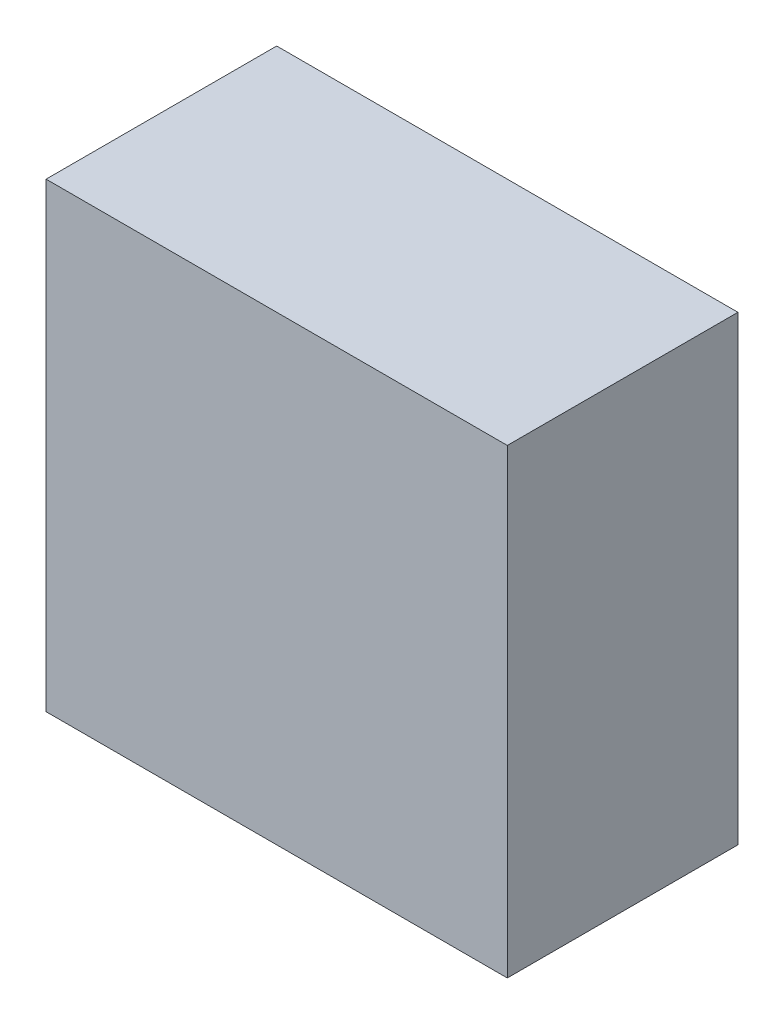
from build123d import *

# Parameters (mm, degrees)
SKETCH1_W           = 60
SKETCH1_H           = 30
BOSS_EXTRUDE1_DEPTH = 60


with BuildPart() as part:
    # Sketch1 → Boss-Extrude1 (new body)
    with BuildSketch(Plane(origin=(0, 0, 0), x_dir=(1, 0, 0), z_dir=(0, 1, 0))):
        Rectangle(SKETCH1_W, SKETCH1_H)
    extrude(amount=BOSS_EXTRUDE1_DEPTH)


solid = part.part
